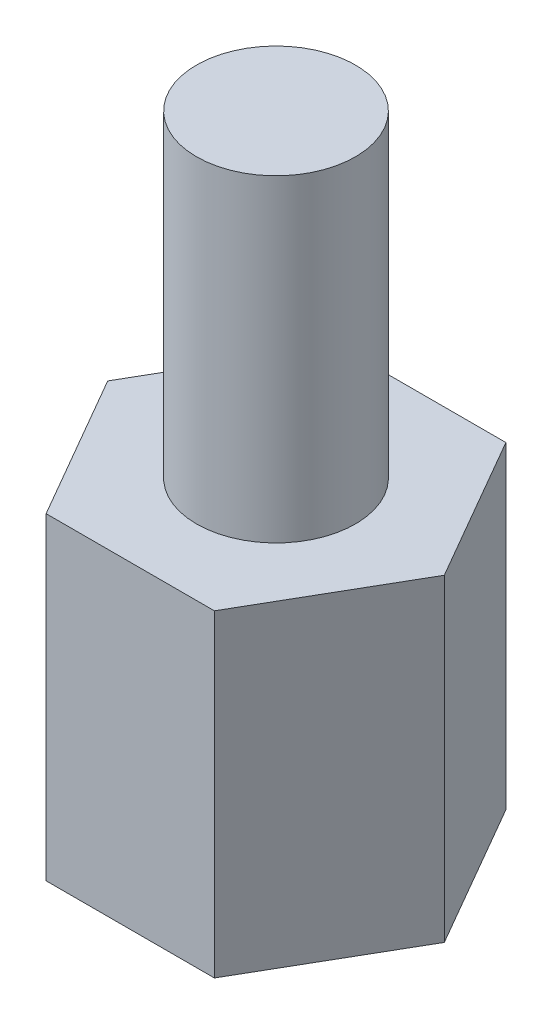
from build123d import *

# Parameters (mm, degrees)
EXTRUDE_1_DEPTH     = 6
SKETCH_2_R          = 1.5
CUT_EXTRUDE_1_DEPTH = 4
SKETCH_3_R          = 1.5
EXTRUDE_2_DEPTH     = 6


with BuildPart() as part:
    # 草图1 → 凸台-拉伸1 (new body)
    with BuildSketch(Plane(origin=(0, 0, 0), x_dir=(1, 0, 0), z_dir=(0, 1, 0))):
        Polygon((3.175426481, 0), (1.58771324, 2.75), (-1.58771324, 2.75), (-3.175426481, 0), (-1.58771324, -2.75), (1.58771324, -2.75), align=None)
    extrude(amount=EXTRUDE_1_DEPTH)

    # 草图2 → 切除-拉伸1 (cut)
    with BuildSketch(Plane.XZ):
        Circle(SKETCH_2_R)
    extrude(amount=-CUT_EXTRUDE_1_DEPTH, mode=Mode.SUBTRACT)

    # 草图3 → 凸台-拉伸2 (add)
    with BuildSketch(Plane(origin=(0, 6, 0), x_dir=(1, 0, 0), z_dir=(0, 1, 0))):
        Circle(SKETCH_3_R)
    extrude(amount=EXTRUDE_2_DEPTH)


solid = part.part
